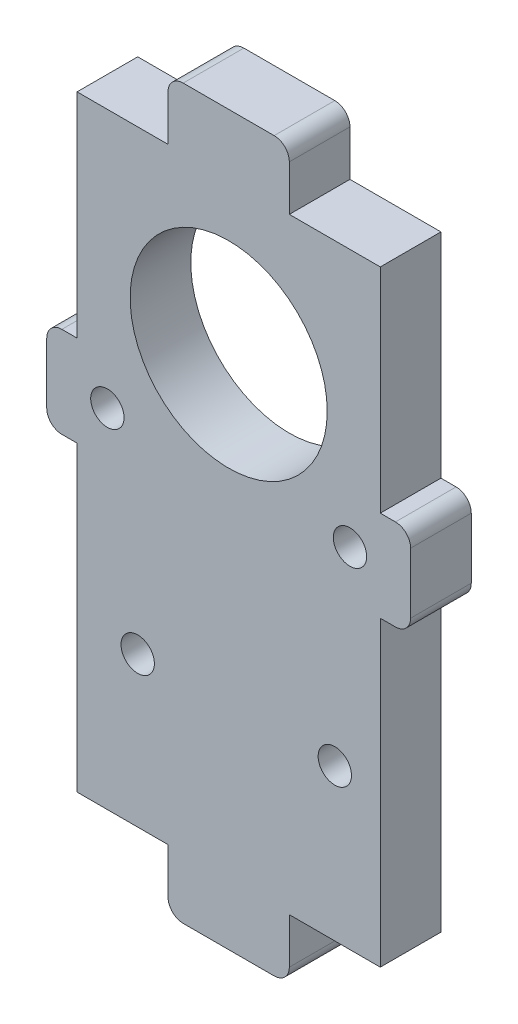
from build123d import *

# Parameters (mm, degrees)
SKETCH1_W           = 20
SKETCH1_H           = 40
SKETCH1_R           = 1.1
SKETCH1_R_2         = 6.5
BOSS_EXTRUDE2_DEPTH = 4


with BuildPart() as part:
    # Sketch1 → Boss-Extrude2 (new body)
    with BuildSketch(Plane.XY):
        Rectangle(SKETCH1_W, SKETCH1_H)
        with Locations((7, -10)):
            Circle(SKETCH1_R, mode=Mode.SUBTRACT)
        with Locations((-6, -10.118141531)):
            Circle(SKETCH1_R, mode=Mode.SUBTRACT)
        with Locations((-8, 2.93366218)):
            Circle(SKETCH1_R, mode=Mode.SUBTRACT)
        with Locations((8, 3)):
            Circle(SKETCH1_R, mode=Mode.SUBTRACT)
        with Locations((0, 10)):
            Circle(SKETCH1_R_2, mode=Mode.SUBTRACT)
        with BuildLine():
            Line((-4, 23), (-4, 20))
            Line((-4, 20), (4, 20))
            Line((4, 20), (4, 23))
            ThreePointArc((4, 23), (3.707106781, 23.707106781), (3, 24))
            Line((3, 24), (-3, 24))
            ThreePointArc((-3, 24), (-3.707106781, 23.707106781), (-4, 23))
        make_face()
        with BuildLine():
            Line((11, 5.93366218), (10, 5.93366218))
            Line((10, 5.93366218), (10, -0.06633782))
            Line((10, -0.06633782), (11, -0.06633782))
            ThreePointArc((11, -0.06633782), (11.707106781, 0.226555399), (12, 0.93366218))
            Line((12, 0.93366218), (12, 4.93366218))
            ThreePointArc((12, 4.93366218), (11.707106781, 5.640768961), (11, 5.93366218))
        make_face()
        with BuildLine():
            Line((4, -20), (-4, -20))
            Line((-4, -20), (-4, -23))
            ThreePointArc((-4, -23), (-3.707106781, -23.707106781), (-3, -24))
            Line((-3, -24), (3, -24))
            ThreePointArc((3, -24), (3.707106781, -23.707106781), (4, -23))
            Line((4, -23), (4, -20))
        make_face()
        with BuildLine():
            Line((-10, -0.06633782), (-10, 5.93366218))
            Line((-10, 5.93366218), (-11, 5.93366218))
            ThreePointArc((-11, 5.93366218), (-11.707106781, 5.640768961), (-12, 4.93366218))
            Line((-12, 4.93366218), (-12, 0.93366218))
            ThreePointArc((-12, 0.93366218), (-11.707106781, 0.226555399), (-11, -0.06633782))
            Line((-11, -0.06633782), (-10, -0.06633782))
        make_face()
    extrude(amount=BOSS_EXTRUDE2_DEPTH)


solid = part.part
